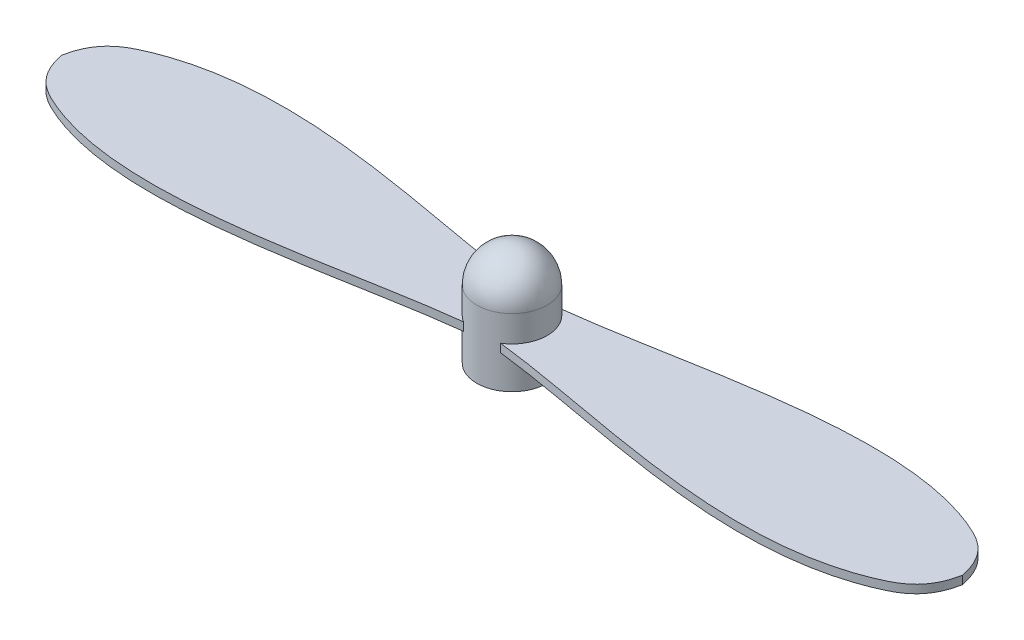
from build123d import *

# Parameters (mm, degrees)
SKETCH1_R           = 2.13
BOSS_EXTRUDE1_DEPTH = 6.22
SKETCH2_R           = 0.5
CUT_EXTRUDE1_DEPTH  = 5
FILLET1_R           = 2.13
BOSS_EXTRUDE2_DEPTH = 0.5


with BuildPart() as part:
    # Sketch1 → Boss-Extrude1 (new body)
    with BuildSketch(Plane(origin=(0, 0, 0), x_dir=(1, 0, 0), z_dir=(0, 1, 0))):
        Circle(SKETCH1_R)
    extrude(amount=BOSS_EXTRUDE1_DEPTH)

    # Sketch2 → Cut-Extrude1 (cut)
    with BuildSketch(Plane.XZ):
        Circle(SKETCH2_R)
    extrude(amount=-CUT_EXTRUDE1_DEPTH, mode=Mode.SUBTRACT)

    # Fillet1
    fillet1_edges = [part.edges().sort_by_distance(p)[0] for p in [
        (-2.13, 6.22, 0),
    ]]
    fillet(fillet1_edges, radius=FILLET1_R)

    # Sketch3 → Boss-Extrude2 (add)
    with BuildSketch(Plane(origin=(0, 2, 0), x_dir=(-1, 0, 0), z_dir=(0, -1, 0))):
        with BuildLine():
            add(Edge.make_bspline(
                [(27.225, 0), (26.883719926, -1.707588045), (19.590217869, -6.21812063), (7.79108972, -2.564670987), (1.121711894, -1.810707714)],
                knots=[0, 0, 0, 0, 0.130362346, 1, 1, 1, 1], degree=3))
            add(Edge.make_bspline(
                [(27.225, 0), (26.883719926, 1.707588045), (19.590217869, 6.21812063), (7.79108972, 2.564670987), (1.121711894, 1.810707714)],
                knots=[0, 0, 0, 0, 0.130362346, 1, 1, 1, 1], degree=3))
            ThreePointArc((1.121711894, 1.810707714), (1.860933413, 1.036256162), (2.13, 0))
            ThreePointArc((2.13, 0), (1.860933413, -1.036256162), (1.121711894, -1.810707714))
        make_face()
        with BuildLine():
            add(Edge.make_bspline(
                [(-27.225, 0), (-26.883719926, 1.707588045), (-19.590217869, 6.21812063), (-7.79108972, 2.564670987), (-1.121711894, 1.810707714)],
                knots=[0, 0, 0, 0, 0.130362346, 1, 1, 1, 1], degree=3))
            add(Edge.make_bspline(
                [(-27.225, 0), (-26.883719926, -1.707588045), (-19.590217869, -6.21812063), (-7.79108972, -2.564670987), (-1.121711894, -1.810707714)],
                knots=[0, 0, 0, 0, 0.130362346, 1, 1, 1, 1], degree=3))
            ThreePointArc((-1.121711894, -1.810707714), (-2.13, 0), (-1.121711894, 1.810707714))
        make_face()
    extrude(amount=-BOSS_EXTRUDE2_DEPTH)


solid = part.part
